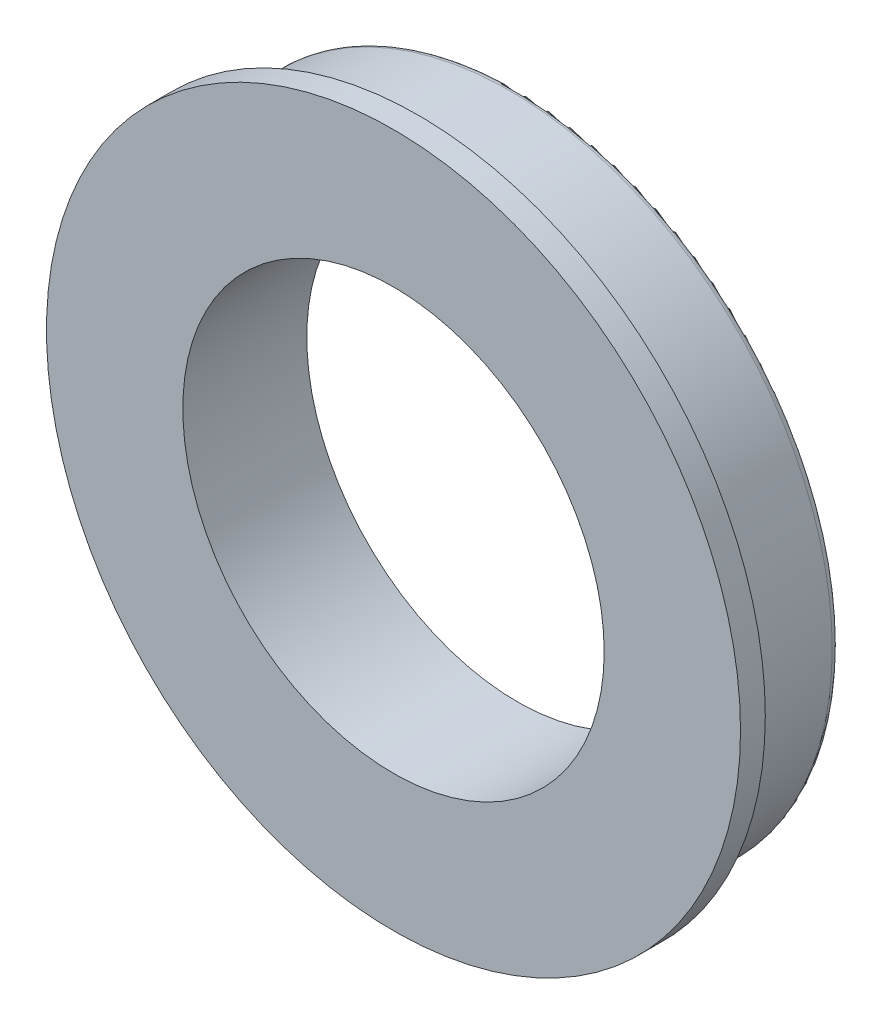
from build123d import *

# Parameters (mm, degrees)
SKETCH_1_R      = 13
SKETCH_1_R_2    = 8.5
EXTRUDE_1_DEPTH = 5
SKETCH_2_R      = 14
SKETCH_2_R_2    = 13
EXTRUDE_2_DEPTH = 1
FILLET_1_R      = 0.3


with BuildPart() as part:
    # 草图1 → 凸台-拉伸1 (new body)
    with BuildSketch(Plane.XY):
        Circle(SKETCH_1_R)
        Circle(SKETCH_1_R_2, mode=Mode.SUBTRACT)
    extrude(amount=EXTRUDE_1_DEPTH)

    # 草图2 → 凸台-拉伸2 (add)
    with BuildSketch(Plane.XY.offset(5)):
        Circle(SKETCH_2_R)
        Circle(SKETCH_2_R_2, mode=Mode.SUBTRACT)
    extrude(amount=-EXTRUDE_2_DEPTH)

    # 圆角1
    fillet_1_edges = [part.edges().sort_by_distance(p)[0] for p in [
        (-13, 0, 0),
    ]]
    fillet(fillet_1_edges, radius=FILLET_1_R)


solid = part.part
